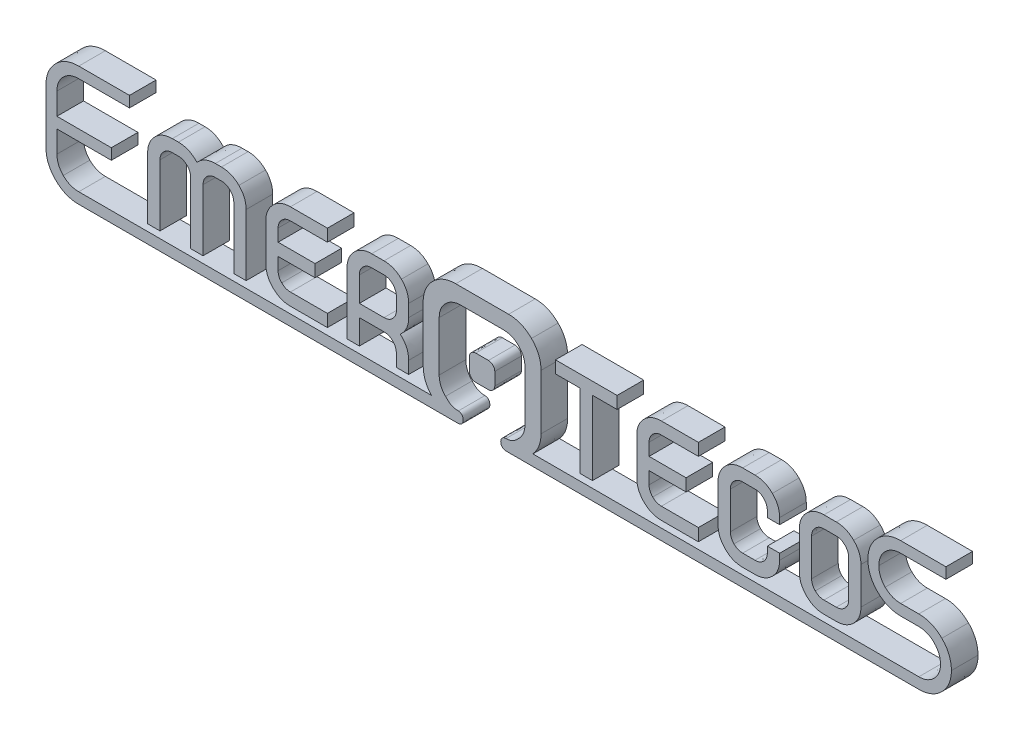
from build123d import *

# Parameters (mm, degrees)
RESSALTO_EXTRUS_O1_DEPTH   = 20
RESSALTO_EXTRUS_O1_2_DEPTH = 20
RESSALTO_EXTRUS_O1_3_DEPTH = 20
RESSALTO_EXTRUS_O1_4_DEPTH = 20
RESSALTO_EXTRUS_O1_5_DEPTH = 20
RESSALTO_EXTRUS_O1_6_DEPTH = 20
RESSALTO_EXTRUS_O1_7_DEPTH = 20
RESSALTO_EXTRUS_O1_8_DEPTH = 20
RESSALTO_EXTRUS_O1_9_DEPTH = 20


with BuildPart() as part:
    # Esboço1 → Ressalto-extrusão1 (new body)
    with BuildSketch(Plane.XY):
        with BuildLine():
            Line((31.801562, 20.64639), (31.801562, -20.646898))
            add(Edge.make_bspline(
                [(31.801562, -20.646898), (31.801562, -26.863802), (29.755084, -32.249618), (25.661874, -36.79825)],
                knots=[0.046153846, 0.046153846, 0.046153846, 0.046153846, 0.061538462, 0.061538462, 0.061538462, 0.061538462], degree=3))
            add(Edge.make_bspline(
                [(25.661874, -36.79825), (122.382026, -36.79825), (219.102432, -36.79825), (315.822584, -36.79825)],
                knots=[0.061538462, 0.061538462, 0.061538462, 0.061538462, 0.076923077, 0.076923077, 0.076923077, 0.076923077], degree=3))
            add(Edge.make_bspline(
                [(315.822584, -36.79825), (320.318384, -36.79825), (324.154546, -35.209988), (327.33107, -32.033718)],
                knots=[0.076923077, 0.076923077, 0.076923077, 0.076923077, 0.092307692, 0.092307692, 0.092307692, 0.092307692], degree=3))
            add(Edge.make_bspline(
                [(327.33107, -32.033718), (330.507594, -28.85694), (332.095856, -25.020778), (332.095856, -20.524978)],
                knots=[0.092307692, 0.092307692, 0.092307692, 0.092307692, 0.107692308, 0.107692308, 0.107692308, 0.107692308], degree=3))
            add(Edge.make_bspline(
                [(332.095856, -20.524978), (332.095856, -15.931134), (330.507594, -12.04595), (327.33107, -8.869426)],
                knots=[0.107692308, 0.107692308, 0.107692308, 0.107692308, 0.123076923, 0.123076923, 0.123076923, 0.123076923], degree=3))
            add(Edge.make_bspline(
                [(327.33107, -8.869426), (324.154546, -5.692902), (320.318384, -4.10464), (315.822584, -4.10464)],
                knots=[0.123076923, 0.123076923, 0.123076923, 0.123076923, 0.138461538, 0.138461538, 0.138461538, 0.138461538], degree=3))
            Line((315.822584, -4.10464), (302.187864, -4.10464))
            add(Edge.make_bspline(
                [(302.187864, -4.10464), (295.346374, -4.10464), (289.531044, -1.710182), (284.74162, 3.078734)],
                knots=[0.153846154, 0.153846154, 0.153846154, 0.153846154, 0.169230769, 0.169230769, 0.169230769, 0.169230769], degree=3))
            add(Edge.make_bspline(
                [(284.74162, 3.078734), (279.95245, 7.868158), (277.558246, 13.683488), (277.558246, 20.525232)],
                knots=[0.169230769, 0.169230769, 0.169230769, 0.169230769, 0.184615385, 0.184615385, 0.184615385, 0.184615385], degree=3))
            add(Edge.make_bspline(
                [(277.558246, 20.525232), (277.558246, 27.269186), (279.95245, 33.035748), (284.74162, 37.824918)],
                knots=[0.184615385, 0.184615385, 0.184615385, 0.184615385, 0.2, 0.2, 0.2, 0.2], degree=3))
            add(Edge.make_bspline(
                [(284.74162, 37.824918), (289.531044, 42.614088), (295.346374, 45.0088), (302.187864, 45.0088)],
                knots=[0.2, 0.2, 0.2, 0.2, 0.215384615, 0.215384615, 0.215384615, 0.215384615], degree=3))
            Line((302.187864, 45.0088), (336.201004, 45.0088))
            Line((336.201004, 45.0088), (336.201004, 36.798504))
            Line((336.201004, 36.798504), (302.187864, 36.798504))
            add(Edge.make_bspline(
                [(302.187864, 36.798504), (297.594274, 36.798504), (293.709344, 35.210242), (290.53282, 32.033718)],
                knots=[0.261538462, 0.261538462, 0.261538462, 0.261538462, 0.276923077, 0.276923077, 0.276923077, 0.276923077], degree=3))
            add(Edge.make_bspline(
                [(290.53282, 32.033718), (287.356296, 28.857448), (285.768034, 25.021032), (285.768034, 20.525232)],
                knots=[0.276923077, 0.276923077, 0.276923077, 0.276923077, 0.292307692, 0.292307692, 0.292307692, 0.292307692], degree=3))
            add(Edge.make_bspline(
                [(285.768034, 20.525232), (285.768034, 15.931388), (287.356296, 12.046458), (290.53282, 8.869934)],
                knots=[0.292307692, 0.292307692, 0.292307692, 0.292307692, 0.307692308, 0.307692308, 0.307692308, 0.307692308], degree=3))
            add(Edge.make_bspline(
                [(290.53282, 8.869934), (293.709344, 5.69341), (297.594274, 4.105148), (302.187864, 4.105148)],
                knots=[0.307692308, 0.307692308, 0.307692308, 0.307692308, 0.323076923, 0.323076923, 0.323076923, 0.323076923], degree=3))
            Line((302.187864, 4.105148), (315.822584, 4.105148))
            add(Edge.make_bspline(
                [(315.822584, 4.105148), (322.566284, 4.105148), (328.3331, 1.710436), (333.12227, -3.078734)],
                knots=[0.338461538, 0.338461538, 0.338461538, 0.338461538, 0.353846154, 0.353846154, 0.353846154, 0.353846154], degree=3))
            add(Edge.make_bspline(
                [(333.12227, -3.078734), (337.91144, -7.86765), (340.306152, -13.683234), (340.306152, -20.524978)],
                knots=[0.353846154, 0.353846154, 0.353846154, 0.353846154, 0.369230769, 0.369230769, 0.369230769, 0.369230769], degree=3))
            add(Edge.make_bspline(
                [(340.306152, -20.524978), (340.306152, -27.268678), (337.91144, -33.03524), (333.12227, -37.82441)],
                knots=[0.369230769, 0.369230769, 0.369230769, 0.369230769, 0.384615385, 0.384615385, 0.384615385, 0.384615385], degree=3))
            add(Edge.make_bspline(
                [(333.12227, -37.82441), (328.3331, -42.61358), (322.566284, -45.008292), (315.822584, -45.008292)],
                knots=[0.384615385, 0.384615385, 0.384615385, 0.384615385, 0.4, 0.4, 0.4, 0.4], degree=3))
            add(Edge.make_bspline(
                [(315.822584, -45.008292), (212.438996, -45.00753), (109.055408, -45.008038), (5.67182, -45.008038)],
                knots=[0.4, 0.4, 0.4, 0.4, 0.415384615, 0.415384615, 0.415384615, 0.415384615], degree=3))
            add(Edge.make_bspline(
                [(5.67182, -45.008038), (0.098044, -45.019722), (0.254254, -36.839144), (5.551678, -36.839144)],
                knots=[0.415384615, 0.415384615, 0.415384615, 0.415384615, 0.430769231, 0.430769231, 0.430769231, 0.430769231], degree=3))
            add(Edge.make_bspline(
                [(5.551678, -36.839144), (10.263378, -36.676076), (11.735562, -35.372802), (15.010384, -32.098234)],
                knots=[0.430769231, 0.430769231, 0.430769231, 0.430769231, 0.446153846, 0.446153846, 0.446153846, 0.446153846], degree=3))
            add(Edge.make_bspline(
                [(15.010384, -32.098234), (18.170906, -28.937458), (19.751294, -25.1206), (19.751294, -20.646898)],
                knots=[0.446153846, 0.446153846, 0.446153846, 0.446153846, 0.461538462, 0.461538462, 0.461538462, 0.461538462], degree=3))
            Line((19.751294, -20.646898), (19.751294, 16.765524))
            add(Edge.make_bspline(
                [(19.751294, 16.765524), (19.751294, 21.238972), (18.170906, 25.056338), (15.010384, 28.21686)],
                knots=[0.476923077, 0.476923077, 0.476923077, 0.476923077, 0.492307692, 0.492307692, 0.492307692, 0.492307692], degree=3))
            add(Edge.make_bspline(
                [(15.010384, 28.21686), (11.849608, 31.377382), (8.029956, 32.95777), (3.559048, 32.95777)],
                knots=[0.492307692, 0.492307692, 0.492307692, 0.492307692, 0.507692308, 0.507692308, 0.507692308, 0.507692308], degree=3))
            Line((3.559048, 32.95777), (-28.38831, 32.95777))
            add(Edge.make_bspline(
                [(-28.38831, 32.95777), (-32.9565, 32.95777), (-36.824666, 31.377382), (-39.985442, 28.21686)],
                knots=[0.523076923, 0.523076923, 0.523076923, 0.523076923, 0.538461538, 0.538461538, 0.538461538, 0.538461538], degree=3))
            add(Edge.make_bspline(
                [(-39.985442, 28.21686), (-43.145964, 25.056338), (-44.726098, 21.237956), (-44.726098, 16.765524)],
                knots=[0.538461538, 0.538461538, 0.538461538, 0.538461538, 0.553846154, 0.553846154, 0.553846154, 0.553846154], degree=3))
            Line((-44.726098, 16.765524), (-44.726098, -20.646898))
            add(Edge.make_bspline(
                [(-44.726098, -20.646898), (-44.726098, -25.119584), (-43.145964, -28.937458), (-39.985442, -32.098234)],
                knots=[0.569230769, 0.569230769, 0.569230769, 0.569230769, 0.584615385, 0.584615385, 0.584615385, 0.584615385], degree=3))
            add(Edge.make_bspline(
                [(-39.985442, -32.098234), (-36.663376, -35.419792), (-35.146488, -36.678108), (-30.38094, -36.839144)],
                knots=[0.584615385, 0.584615385, 0.584615385, 0.584615385, 0.6, 0.6, 0.6, 0.6], degree=3))
            add(Edge.make_bspline(
                [(-30.38094, -36.839144), (-25.404826, -36.839144), (-25.404826, -45.008292), (-30.38094, -45.008292)],
                knots=[0.6, 0.6, 0.6, 0.6, 0.615384615, 0.615384615, 0.615384615, 0.615384615], degree=3))
            add(Edge.make_bspline(
                [(-30.38094, -45.008292), (-125.479302, -45.008292), (-220.577918, -45.008292), (-315.67628, -45.008292)],
                knots=[0.615384615, 0.615384615, 0.615384615, 0.615384615, 0.630769231, 0.630769231, 0.630769231, 0.630769231], degree=3))
            add(Edge.make_bspline(
                [(-315.67628, -45.008292), (-322.51777, -45.008292), (-328.333354, -42.61358), (-333.12227, -37.82441)],
                knots=[0.630769231, 0.630769231, 0.630769231, 0.630769231, 0.646153846, 0.646153846, 0.646153846, 0.646153846], degree=3))
            add(Edge.make_bspline(
                [(-333.12227, -37.82441), (-337.91144, -33.035494), (-340.305898, -27.268678), (-340.305898, -20.524978)],
                knots=[0.646153846, 0.646153846, 0.646153846, 0.646153846, 0.661538462, 0.661538462, 0.661538462, 0.661538462], degree=3))
            Line((-340.305898, -20.524978), (-340.305898, 20.524724))
            add(Edge.make_bspline(
                [(-340.305898, 20.524724), (-340.305898, 27.268424), (-337.91144, 33.03524), (-333.12227, 37.824156)],
                knots=[0.676923077, 0.676923077, 0.676923077, 0.676923077, 0.692307692, 0.692307692, 0.692307692, 0.692307692], degree=3))
            add(Edge.make_bspline(
                [(-333.12227, 37.824156), (-328.333354, 42.613326), (-322.51777, 45.008038), (-315.67628, 45.008038)],
                knots=[0.692307692, 0.692307692, 0.692307692, 0.692307692, 0.707692308, 0.707692308, 0.707692308, 0.707692308], degree=3))
            Line((-315.67628, 45.008038), (-277.5585, 45.008038))
            Line((-277.5585, 45.008038), (-277.5585, 36.797742))
            Line((-277.5585, 36.797742), (-315.67628, 36.797742))
            add(Edge.make_bspline(
                [(-315.67628, 36.797742), (-320.26987, 36.797742), (-324.1548, 35.209734), (-327.331324, 32.03321)],
                knots=[0.753846154, 0.753846154, 0.753846154, 0.753846154, 0.769230769, 0.769230769, 0.769230769, 0.769230769], degree=3))
            add(Edge.make_bspline(
                [(-327.331324, 32.03321), (-330.507848, 28.856686), (-332.095856, 25.020524), (-332.095856, 20.524724)],
                knots=[0.769230769, 0.769230769, 0.769230769, 0.769230769, 0.784615385, 0.784615385, 0.784615385, 0.784615385], degree=3))
            Line((-332.095856, 20.524724), (-332.095856, 4.104894))
            Line((-332.095856, 4.104894), (-291.192966, 4.104894))
            Line((-291.192966, 4.104894), (-291.192966, -4.105148))
            Line((-291.192966, -4.105148), (-332.095856, -4.105148))
            Line((-332.095856, -4.105148), (-332.095856, -20.524978))
            add(Edge.make_bspline(
                [(-332.095856, -20.524978), (-332.095856, -25.021032), (-330.507848, -28.85694), (-327.331324, -32.033718)],
                knots=[0.861538462, 0.861538462, 0.861538462, 0.861538462, 0.876923077, 0.876923077, 0.876923077, 0.876923077], degree=3))
            add(Edge.make_bspline(
                [(-327.331324, -32.033718), (-324.1548, -35.210242), (-320.26987, -36.798504), (-315.67628, -36.798504)],
                knots=[0.876923077, 0.876923077, 0.876923077, 0.876923077, 0.892307692, 0.892307692, 0.892307692, 0.892307692], degree=3))
            add(Edge.make_bspline(
                [(-315.67628, -36.798504), (-227.329746, -36.798504), (-138.982958, -36.798504), (-50.636424, -36.798504)],
                knots=[0.892307692, 0.892307692, 0.892307692, 0.892307692, 0.907692308, 0.907692308, 0.907692308, 0.907692308], degree=3))
            add(Edge.make_bspline(
                [(-50.636424, -36.798504), (-54.729888, -32.250126), (-56.776366, -26.866342), (-56.776366, -20.646898)],
                knots=[0.907692308, 0.907692308, 0.907692308, 0.907692308, 0.923076923, 0.923076923, 0.923076923, 0.923076923], degree=3))
            Line((-56.776366, -20.646898), (-56.776366, 20.64639))
            add(Edge.make_bspline(
                [(-56.776366, 20.64639), (-56.776366, 27.356562), (-54.393846, 33.094422), (-49.628552, 37.859716)],
                knots=[0.938461538, 0.938461538, 0.938461538, 0.938461538, 0.953846154, 0.953846154, 0.953846154, 0.953846154], degree=3))
            add(Edge.make_bspline(
                [(-49.628552, 37.859716), (-44.863258, 42.62501), (-39.076884, 45.007784), (-32.26943, 45.007784)],
                knots=[0.953846154, 0.953846154, 0.953846154, 0.953846154, 0.969230769, 0.969230769, 0.969230769, 0.969230769], degree=3))
            Line((-32.26943, 45.007784), (7.440422, 45.007784))
            add(Edge.make_bspline(
                [(7.440422, 45.007784), (14.150594, 45.007784), (19.888454, 42.62501), (24.653748, 37.859716)],
                knots=[0, 0, 0, 0, 0.015384615, 0.015384615, 0.015384615, 0.015384615], degree=3))
            add(Edge.make_bspline(
                [(24.653748, 37.859716), (29.419042, 33.094422), (31.801562, 27.354276), (31.801562, 20.64639)],
                knots=[0.015384615, 0.015384615, 0.015384615, 0.015384615, 0.030769231, 0.030769231, 0.030769231, 0.030769231], degree=3))
        make_face()
    extrude(amount=RESSALTO_EXTRUS_O1_DEPTH)


with BuildPart() as body_2:
    # Esboço1 → Ressalto-extrus_o1 2 (new body)
    with BuildSketch(Plane.XY):
        with BuildLine():
            Line((-17.256252, 7.376922), (-7.718044, 7.376922))
            add(Edge.make_bspline(
                [(-7.718044, 7.376922), (-5.094986, 7.376922), (-2.949194, 5.23113), (-2.949194, 2.608326)],
                knots=[0.111111111, 0.111111111, 0.111111111, 0.111111111, 0.222222222, 0.222222222, 0.222222222, 0.222222222], degree=3))
            Line((-2.949194, 2.608326), (-2.949194, -6.930136))
            add(Edge.make_bspline(
                [(-2.949194, -6.930136), (-2.949194, -9.55294), (-5.094986, -11.698732), (-7.718044, -11.698732)],
                knots=[0.333333333, 0.333333333, 0.333333333, 0.333333333, 0.444444444, 0.444444444, 0.444444444, 0.444444444], degree=3))
            Line((-7.718044, -11.698732), (-17.256252, -11.698732))
            add(Edge.make_bspline(
                [(-17.256252, -11.698732), (-19.879056, -11.698732), (-22.024848, -9.55294), (-22.024848, -6.930136)],
                knots=[0.555555556, 0.555555556, 0.555555556, 0.555555556, 0.666666667, 0.666666667, 0.666666667, 0.666666667], degree=3))
            Line((-22.024848, -6.930136), (-22.024848, 2.608326))
            add(Edge.make_bspline(
                [(-22.024848, 2.608326), (-22.024848, 5.23113), (-19.879056, 7.376922), (-17.256252, 7.376922)],
                knots=[0.777777778, 0.777777778, 0.777777778, 0.777777778, 1, 1, 1, 1], degree=3))
        make_face()
    extrude(amount=RESSALTO_EXTRUS_O1_2_DEPTH)


with BuildPart() as body_3:
    # Esboço1 → Ressalto-extrus_o1 3 (new body)
    with BuildSketch(Plane.XY):
        with BuildLine():
            Line((253.772416, -31.785052), (244.508528, -31.785052))
            add(Edge.make_bspline(
                [(244.508528, -31.785052), (239.373664, -31.785052), (235.001816, -29.980636), (231.393492, -26.372312)],
                knots=[0.230769231, 0.230769231, 0.230769231, 0.230769231, 0.307692308, 0.307692308, 0.307692308, 0.307692308], degree=3))
            add(Edge.make_bspline(
                [(231.393492, -26.372312), (227.785168, -22.763988), (225.981006, -18.392394), (225.981006, -13.257276)],
                knots=[0.307692308, 0.307692308, 0.307692308, 0.307692308, 0.384615385, 0.384615385, 0.384615385, 0.384615385], degree=3))
            Line((225.981006, -13.257276), (225.981006, 14.534134))
            add(Edge.make_bspline(
                [(225.981006, 14.534134), (225.981006, 19.59991), (227.785168, 23.936706), (231.393492, 27.545284)],
                knots=[0.461538462, 0.461538462, 0.461538462, 0.461538462, 0.538461538, 0.538461538, 0.538461538, 0.538461538], degree=3))
            add(Edge.make_bspline(
                [(231.393492, 27.545284), (235.001816, 31.153608), (239.373664, 32.95777), (244.508528, 32.95777)],
                knots=[0.538461538, 0.538461538, 0.538461538, 0.538461538, 0.615384615, 0.615384615, 0.615384615, 0.615384615], degree=3))
            Line((244.508528, 32.95777), (253.772416, 32.95777))
            add(Edge.make_bspline(
                [(253.772416, 32.95777), (258.837938, 32.95777), (263.19226, 31.153608), (266.835382, 27.545284)],
                knots=[0.692307692, 0.692307692, 0.692307692, 0.692307692, 0.769230769, 0.769230769, 0.769230769, 0.769230769], degree=3))
            add(Edge.make_bspline(
                [(266.835382, 27.545284), (270.478504, 23.936706), (272.300192, 19.59991), (272.300192, 14.534134)],
                knots=[0.769230769, 0.769230769, 0.769230769, 0.769230769, 0.846153846, 0.846153846, 0.846153846, 0.846153846], degree=3))
            Line((272.300192, 14.534134), (272.300192, -13.257276))
            add(Edge.make_bspline(
                [(272.300192, -13.257276), (272.300192, -18.392394), (270.478504, -22.763988), (266.835382, -26.372312)],
                knots=[0, 0, 0, 0, 0.076923077, 0.076923077, 0.076923077, 0.076923077], degree=3))
            add(Edge.make_bspline(
                [(266.835382, -26.372312), (263.19226, -29.980636), (258.837938, -31.785052), (253.772416, -31.785052)],
                knots=[0.076923077, 0.076923077, 0.076923077, 0.076923077, 0.153846154, 0.153846154, 0.153846154, 0.153846154], degree=3))
        make_face()
        with BuildLine():
            Line((263.036304, -13.257276), (263.036304, 14.534134))
            add(Edge.make_bspline(
                [(263.036304, 14.534134), (263.036304, 17.032224), (262.134096, 19.200876), (260.329934, 21.039836)],
                knots=[0.076923077, 0.076923077, 0.076923077, 0.076923077, 0.153846154, 0.153846154, 0.153846154, 0.153846154], degree=3))
            add(Edge.make_bspline(
                [(260.329934, 21.039836), (258.525772, 22.878542), (256.339848, 23.798022), (253.772416, 23.798022)],
                knots=[0.153846154, 0.153846154, 0.153846154, 0.153846154, 0.230769231, 0.230769231, 0.230769231, 0.230769231], degree=3))
            Line((253.772416, 23.798022), (244.508528, 23.798022))
            add(Edge.make_bspline(
                [(244.508528, 23.798022), (241.941096, 23.798022), (239.755172, 22.878542), (237.95101, 21.039836)],
                knots=[0.307692308, 0.307692308, 0.307692308, 0.307692308, 0.384615385, 0.384615385, 0.384615385, 0.384615385], degree=3))
            add(Edge.make_bspline(
                [(237.95101, 21.039836), (236.146594, 19.200876), (235.24464, 17.032224), (235.24464, 14.534134)],
                knots=[0.384615385, 0.384615385, 0.384615385, 0.384615385, 0.461538462, 0.461538462, 0.461538462, 0.461538462], degree=3))
            Line((235.24464, 14.534134), (235.24464, -13.257276))
            add(Edge.make_bspline(
                [(235.24464, -13.257276), (235.24464, -15.824962), (236.146594, -18.010632), (237.95101, -19.815048)],
                knots=[0.538461538, 0.538461538, 0.538461538, 0.538461538, 0.615384615, 0.615384615, 0.615384615, 0.615384615], degree=3))
            add(Edge.make_bspline(
                [(237.95101, -19.815048), (239.755172, -21.618956), (241.941096, -22.521164), (244.508528, -22.521164)],
                knots=[0.615384615, 0.615384615, 0.615384615, 0.615384615, 0.692307692, 0.692307692, 0.692307692, 0.692307692], degree=3))
            Line((244.508528, -22.521164), (253.772416, -22.521164))
            add(Edge.make_bspline(
                [(253.772416, -22.521164), (256.339848, -22.521164), (258.525772, -21.618956), (260.329934, -19.815048)],
                knots=[0.769230769, 0.769230769, 0.769230769, 0.769230769, 0.846153846, 0.846153846, 0.846153846, 0.846153846], degree=3))
            add(Edge.make_bspline(
                [(260.329934, -19.815048), (262.134096, -18.010632), (263.036304, -15.824962), (263.036304, -13.257276)],
                knots=[0.846153846, 0.846153846, 0.846153846, 0.846153846, 1, 1, 1, 1], degree=3))
        make_face(mode=Mode.SUBTRACT)
    extrude(amount=RESSALTO_EXTRUS_O1_3_DEPTH)


with BuildPart() as body_4:
    # Esboço1 → Ressalto-extrus_o1 4 (new body)
    with BuildSketch(Plane.XY):
        with BuildLine():
            Line((-67.67576, -31.785052), (-76.939648, -31.785052))
            Line((-76.939648, -31.785052), (-76.939648, -22.521164))
            add(Edge.make_bspline(
                [(-76.939648, -22.521164), (-76.939648, -19.953732), (-77.841856, -17.767808), (-79.646018, -15.963646)],
                knots=[0.111111111, 0.111111111, 0.111111111, 0.111111111, 0.166666667, 0.166666667, 0.166666667, 0.166666667], degree=3))
            add(Edge.make_bspline(
                [(-79.646018, -15.963646), (-81.450434, -14.159484), (-83.636104, -13.257276), (-86.203536, -13.257276)],
                knots=[0.166666667, 0.166666667, 0.166666667, 0.166666667, 0.222222222, 0.222222222, 0.222222222, 0.222222222], degree=3))
            Line((-86.203536, -13.257276), (-104.731312, -13.257276))
            Line((-104.731312, -13.257276), (-104.731312, -31.785052))
            Line((-104.731312, -31.785052), (-113.994946, -31.785052))
            Line((-113.994946, -31.785052), (-113.994946, 14.534134))
            add(Edge.make_bspline(
                [(-113.994946, 14.534134), (-113.994946, 19.59991), (-112.190784, 23.936706), (-108.58246, 27.545284)],
                knots=[0.444444444, 0.444444444, 0.444444444, 0.444444444, 0.5, 0.5, 0.5, 0.5], degree=3))
            add(Edge.make_bspline(
                [(-108.58246, 27.545284), (-104.974136, 31.153608), (-100.602288, 32.95777), (-95.467424, 32.95777)],
                knots=[0.5, 0.5, 0.5, 0.5, 0.555555556, 0.555555556, 0.555555556, 0.555555556], degree=3))
            Line((-95.467424, 32.95777), (-86.203536, 32.95777))
            add(Edge.make_bspline(
                [(-86.203536, 32.95777), (-81.138014, 32.95777), (-76.783692, 31.153608), (-73.14057, 27.545284)],
                knots=[0.611111111, 0.611111111, 0.611111111, 0.611111111, 0.666666667, 0.666666667, 0.666666667, 0.666666667], degree=3))
            add(Edge.make_bspline(
                [(-73.14057, 27.545284), (-69.497448, 23.936706), (-67.67576, 19.59991), (-67.67576, 14.534134)],
                knots=[0.666666667, 0.666666667, 0.666666667, 0.666666667, 0.722222222, 0.722222222, 0.722222222, 0.722222222], degree=3))
            Line((-67.67576, 14.534134), (-67.67576, 5.2705))
            add(Edge.make_bspline(
                [(-67.67576, 5.2705), (-67.67576, -0.350266), (-69.792342, -4.999736), (-74.025506, -8.677402)],
                knots=[0.777777778, 0.777777778, 0.777777778, 0.777777778, 0.833333333, 0.833333333, 0.833333333, 0.833333333], degree=3))
            add(Edge.make_bspline(
                [(-74.025506, -8.677402), (-69.792342, -12.355068), (-67.67576, -16.96974), (-67.67576, -22.521164)],
                knots=[0.833333333, 0.833333333, 0.833333333, 0.833333333, 0.888888889, 0.888888889, 0.888888889, 0.888888889], degree=3))
            Line((-67.67576, -22.521164), (-67.67576, -31.785052))
        make_face()
        with BuildLine():
            Line((-76.939648, 5.2705), (-76.939648, 14.534134))
            add(Edge.make_bspline(
                [(-76.939648, 14.534134), (-76.939648, 17.032224), (-77.841856, 19.200876), (-79.646018, 21.039836)],
                knots=[0.090909091, 0.090909091, 0.090909091, 0.090909091, 0.181818182, 0.181818182, 0.181818182, 0.181818182], degree=3))
            add(Edge.make_bspline(
                [(-79.646018, 21.039836), (-81.450434, 22.878542), (-83.636104, 23.798022), (-86.203536, 23.798022)],
                knots=[0.181818182, 0.181818182, 0.181818182, 0.181818182, 0.272727273, 0.272727273, 0.272727273, 0.272727273], degree=3))
            Line((-86.203536, 23.798022), (-95.467424, 23.798022))
            add(Edge.make_bspline(
                [(-95.467424, 23.798022), (-98.034856, 23.798022), (-100.22078, 22.878542), (-102.024942, 21.039836)],
                knots=[0.363636364, 0.363636364, 0.363636364, 0.363636364, 0.454545455, 0.454545455, 0.454545455, 0.454545455], degree=3))
            add(Edge.make_bspline(
                [(-102.024942, 21.039836), (-103.829358, 19.200876), (-104.731312, 17.032224), (-104.731312, 14.534134)],
                knots=[0.454545455, 0.454545455, 0.454545455, 0.454545455, 0.545454545, 0.545454545, 0.545454545, 0.545454545], degree=3))
            Line((-104.731312, 14.534134), (-104.731312, -3.993388))
            Line((-104.731312, -3.993388), (-86.203536, -3.993388))
            add(Edge.make_bspline(
                [(-86.203536, -3.993388), (-83.636104, -3.993388), (-81.450434, -3.091434), (-79.646018, -1.287018)],
                knots=[0.727272727, 0.727272727, 0.727272727, 0.727272727, 0.818181818, 0.818181818, 0.818181818, 0.818181818], degree=3))
            add(Edge.make_bspline(
                [(-79.646018, -1.287018), (-77.841856, 0.517144), (-76.939648, 2.703068), (-76.939648, 5.2705)],
                knots=[0.818181818, 0.818181818, 0.818181818, 0.818181818, 1, 1, 1, 1], degree=3))
        make_face(mode=Mode.SUBTRACT)
    extrude(amount=RESSALTO_EXTRUS_O1_4_DEPTH)


with BuildPart() as body_5:
    # Esboço1 → Ressalto-extrus_o1 5 (new body)
    with BuildSketch(Plane.XY):
        with BuildLine():
            Line((192.672716, -31.785052), (183.408828, -31.785052))
            add(Edge.make_bspline(
                [(183.408828, -31.785052), (178.273964, -31.785052), (173.90237, -29.980636), (170.293792, -26.372312)],
                knots=[0.103448276, 0.103448276, 0.103448276, 0.103448276, 0.137931034, 0.137931034, 0.137931034, 0.137931034], degree=3))
            add(Edge.make_bspline(
                [(170.293792, -26.372312), (166.685468, -22.763988), (164.881306, -18.392394), (164.881306, -13.257276)],
                knots=[0.137931034, 0.137931034, 0.137931034, 0.137931034, 0.172413793, 0.172413793, 0.172413793, 0.172413793], degree=3))
            Line((164.881306, -13.257276), (164.881306, 14.534134))
            add(Edge.make_bspline(
                [(164.881306, 14.534134), (164.881306, 19.59991), (166.685468, 23.936706), (170.293792, 27.545284)],
                knots=[0.206896552, 0.206896552, 0.206896552, 0.206896552, 0.24137931, 0.24137931, 0.24137931, 0.24137931], degree=3))
            add(Edge.make_bspline(
                [(170.293792, 27.545284), (173.90237, 31.153608), (178.273964, 32.95777), (183.408828, 32.95777)],
                knots=[0.24137931, 0.24137931, 0.24137931, 0.24137931, 0.275862069, 0.275862069, 0.275862069, 0.275862069], degree=3))
            Line((183.408828, 32.95777), (192.672716, 32.95777))
            add(Edge.make_bspline(
                [(192.672716, 32.95777), (197.738492, 32.95777), (202.092814, 31.153608), (205.735682, 27.545284)],
                knots=[0.310344828, 0.310344828, 0.310344828, 0.310344828, 0.344827586, 0.344827586, 0.344827586, 0.344827586], degree=3))
            add(Edge.make_bspline(
                [(205.735682, 27.545284), (209.378804, 23.936706), (211.200492, 19.59991), (211.200492, 14.534134)],
                knots=[0.344827586, 0.344827586, 0.344827586, 0.344827586, 0.379310345, 0.379310345, 0.379310345, 0.379310345], degree=3))
            Line((211.200492, 14.534134), (211.200492, 9.85012))
            Line((211.200492, 9.85012), (201.936858, 9.85012))
            Line((201.936858, 9.85012), (201.936858, 14.534134))
            add(Edge.make_bspline(
                [(201.936858, 14.534134), (201.936858, 17.032224), (201.034396, 19.200876), (199.230234, 21.039836)],
                knots=[0.482758621, 0.482758621, 0.482758621, 0.482758621, 0.517241379, 0.517241379, 0.517241379, 0.517241379], degree=3))
            add(Edge.make_bspline(
                [(199.230234, 21.039836), (197.426072, 22.878542), (195.240148, 23.798022), (192.672716, 23.798022)],
                knots=[0.517241379, 0.517241379, 0.517241379, 0.517241379, 0.551724138, 0.551724138, 0.551724138, 0.551724138], degree=3))
            Line((192.672716, 23.798022), (183.408828, 23.798022))
            add(Edge.make_bspline(
                [(183.408828, 23.798022), (180.841396, 23.798022), (178.655472, 22.878542), (176.85131, 21.039836)],
                knots=[0.586206897, 0.586206897, 0.586206897, 0.586206897, 0.620689655, 0.620689655, 0.620689655, 0.620689655], degree=3))
            add(Edge.make_bspline(
                [(176.85131, 21.039836), (175.047148, 19.200876), (174.145194, 17.032224), (174.145194, 14.534134)],
                knots=[0.620689655, 0.620689655, 0.620689655, 0.620689655, 0.655172414, 0.655172414, 0.655172414, 0.655172414], degree=3))
            Line((174.145194, 14.534134), (174.145194, -13.257276))
            add(Edge.make_bspline(
                [(174.145194, -13.257276), (174.145194, -15.824962), (175.047148, -18.010632), (176.85131, -19.815048)],
                knots=[0.689655172, 0.689655172, 0.689655172, 0.689655172, 0.724137931, 0.724137931, 0.724137931, 0.724137931], degree=3))
            add(Edge.make_bspline(
                [(176.85131, -19.815048), (178.655472, -21.618956), (180.841396, -22.521164), (183.408828, -22.521164)],
                knots=[0.724137931, 0.724137931, 0.724137931, 0.724137931, 0.75862069, 0.75862069, 0.75862069, 0.75862069], degree=3))
            Line((183.408828, -22.521164), (192.672716, -22.521164))
            add(Edge.make_bspline(
                [(192.672716, -22.521164), (195.240148, -22.521164), (197.426072, -21.618956), (199.230234, -19.815048)],
                knots=[0.793103448, 0.793103448, 0.793103448, 0.793103448, 0.827586207, 0.827586207, 0.827586207, 0.827586207], degree=3))
            add(Edge.make_bspline(
                [(199.230234, -19.815048), (201.034396, -18.010632), (201.936858, -15.824962), (201.936858, -13.257276)],
                knots=[0.827586207, 0.827586207, 0.827586207, 0.827586207, 0.862068966, 0.862068966, 0.862068966, 0.862068966], degree=3))
            Line((201.936858, -13.257276), (201.936858, -8.677402))
            Line((201.936858, -8.677402), (211.200492, -8.677402))
            Line((211.200492, -8.677402), (211.200492, -13.257276))
            add(Edge.make_bspline(
                [(211.200492, -13.257276), (211.200492, -18.392394), (209.378804, -22.763988), (205.735682, -26.372312)],
                knots=[0, 0, 0, 0, 0.034482759, 0.034482759, 0.034482759, 0.034482759], degree=3))
            add(Edge.make_bspline(
                [(205.735682, -26.372312), (202.092814, -29.980636), (197.738492, -31.785052), (192.672716, -31.785052)],
                knots=[0.034482759, 0.034482759, 0.034482759, 0.034482759, 0.068965517, 0.068965517, 0.068965517, 0.068965517], degree=3))
        make_face()
    extrude(amount=RESSALTO_EXTRUS_O1_5_DEPTH)


with BuildPart() as body_6:
    # Esboço1 → Ressalto-extrus_o1 6 (new body)
    with BuildSketch(Plane.XY):
        with BuildLine():
            Line((150.101046, -31.785052), (122.309382, -31.785052))
            add(Edge.make_bspline(
                [(122.309382, -31.785052), (117.174264, -31.785052), (112.80267, -29.980636), (109.194092, -26.372312)],
                knots=[0.047619048, 0.047619048, 0.047619048, 0.047619048, 0.095238095, 0.095238095, 0.095238095, 0.095238095], degree=3))
            add(Edge.make_bspline(
                [(109.194092, -26.372312), (105.586022, -22.763988), (103.78186, -18.392394), (103.78186, -13.257276)],
                knots=[0.095238095, 0.095238095, 0.095238095, 0.095238095, 0.142857143, 0.142857143, 0.142857143, 0.142857143], degree=3))
            Line((103.78186, -13.257276), (103.78186, 14.534134))
            add(Edge.make_bspline(
                [(103.78186, 14.534134), (103.78186, 19.59991), (105.586022, 23.936706), (109.194092, 27.545284)],
                knots=[0.19047619, 0.19047619, 0.19047619, 0.19047619, 0.238095238, 0.238095238, 0.238095238, 0.238095238], degree=3))
            add(Edge.make_bspline(
                [(109.194092, 27.545284), (112.80267, 31.153608), (117.174264, 32.95777), (122.309382, 32.95777)],
                knots=[0.238095238, 0.238095238, 0.238095238, 0.238095238, 0.285714286, 0.285714286, 0.285714286, 0.285714286], degree=3))
            Line((122.309382, 32.95777), (150.101046, 32.95777))
            Line((150.101046, 32.95777), (150.101046, 23.798022))
            Line((150.101046, 23.798022), (122.309382, 23.798022))
            add(Edge.make_bspline(
                [(122.309382, 23.798022), (119.74195, 23.798022), (117.556026, 22.878542), (115.751864, 21.039836)],
                knots=[0.428571429, 0.428571429, 0.428571429, 0.428571429, 0.476190476, 0.476190476, 0.476190476, 0.476190476], degree=3))
            add(Edge.make_bspline(
                [(115.751864, 21.039836), (113.947448, 19.200876), (113.045494, 17.032224), (113.045494, 14.534134)],
                knots=[0.476190476, 0.476190476, 0.476190476, 0.476190476, 0.523809524, 0.523809524, 0.523809524, 0.523809524], degree=3))
            Line((113.045494, 14.534134), (113.045494, 5.2705))
            Line((113.045494, 5.2705), (140.837158, 5.2705))
            Line((140.837158, 5.2705), (140.837158, -3.993388))
            Line((140.837158, -3.993388), (113.045494, -3.993388))
            Line((113.045494, -3.993388), (113.045494, -13.257276))
            add(Edge.make_bspline(
                [(113.045494, -13.257276), (113.045494, -15.824962), (113.947448, -18.010632), (115.751864, -19.815048)],
                knots=[0.761904762, 0.761904762, 0.761904762, 0.761904762, 0.80952381, 0.80952381, 0.80952381, 0.80952381], degree=3))
            add(Edge.make_bspline(
                [(115.751864, -19.815048), (117.556026, -21.618956), (119.74195, -22.521164), (122.309382, -22.521164)],
                knots=[0.80952381, 0.80952381, 0.80952381, 0.80952381, 0.857142857, 0.857142857, 0.857142857, 0.857142857], degree=3))
            Line((122.309382, -22.521164), (150.101046, -22.521164))
            Line((150.101046, -22.521164), (150.101046, -31.785052))
        make_face()
    extrude(amount=RESSALTO_EXTRUS_O1_6_DEPTH)


with BuildPart() as body_7:
    # Esboço1 → Ressalto-extrus_o1 7 (new body)
    with BuildSketch(Plane.XY):
        Polygon((89.001346, 23.798022), (70.47357, 23.798022), (70.47357, -31.785052), (61.209682, -31.785052), (61.209682, 23.798022), (42.68216, 23.798022), (42.68216, 32.95777), (89.001346, 32.95777), align=None)
    extrude(amount=RESSALTO_EXTRUS_O1_7_DEPTH)


with BuildPart() as body_8:
    # Esboço1 → Ressalto-extrus_o1 8 (new body)
    with BuildSketch(Plane.XY):
        with BuildLine():
            Line((-128.77546, -31.785052), (-156.567124, -31.785052))
            add(Edge.make_bspline(
                [(-156.567124, -31.785052), (-161.701988, -31.785052), (-166.073836, -29.980636), (-169.68216, -26.372312)],
                knots=[0.047619048, 0.047619048, 0.047619048, 0.047619048, 0.095238095, 0.095238095, 0.095238095, 0.095238095], degree=3))
            add(Edge.make_bspline(
                [(-169.68216, -26.372312), (-173.290484, -22.763988), (-175.094646, -18.392394), (-175.094646, -13.257276)],
                knots=[0.095238095, 0.095238095, 0.095238095, 0.095238095, 0.142857143, 0.142857143, 0.142857143, 0.142857143], degree=3))
            Line((-175.094646, -13.257276), (-175.094646, 14.534134))
            add(Edge.make_bspline(
                [(-175.094646, 14.534134), (-175.094646, 19.59991), (-173.290484, 23.936706), (-169.68216, 27.545284)],
                knots=[0.19047619, 0.19047619, 0.19047619, 0.19047619, 0.238095238, 0.238095238, 0.238095238, 0.238095238], degree=3))
            add(Edge.make_bspline(
                [(-169.68216, 27.545284), (-166.073836, 31.153608), (-161.701988, 32.95777), (-156.567124, 32.95777)],
                knots=[0.238095238, 0.238095238, 0.238095238, 0.238095238, 0.285714286, 0.285714286, 0.285714286, 0.285714286], degree=3))
            Line((-156.567124, 32.95777), (-128.77546, 32.95777))
            Line((-128.77546, 32.95777), (-128.77546, 23.798022))
            Line((-128.77546, 23.798022), (-156.567124, 23.798022))
            add(Edge.make_bspline(
                [(-156.567124, 23.798022), (-159.134556, 23.798022), (-161.32048, 22.878542), (-163.124642, 21.039836)],
                knots=[0.428571429, 0.428571429, 0.428571429, 0.428571429, 0.476190476, 0.476190476, 0.476190476, 0.476190476], degree=3))
            add(Edge.make_bspline(
                [(-163.124642, 21.039836), (-164.928804, 19.200876), (-165.830758, 17.032224), (-165.830758, 14.534134)],
                knots=[0.476190476, 0.476190476, 0.476190476, 0.476190476, 0.523809524, 0.523809524, 0.523809524, 0.523809524], degree=3))
            Line((-165.830758, 14.534134), (-165.830758, 5.2705))
            Line((-165.830758, 5.2705), (-138.039094, 5.2705))
            Line((-138.039094, 5.2705), (-138.039094, -3.993388))
            Line((-138.039094, -3.993388), (-165.830758, -3.993388))
            Line((-165.830758, -3.993388), (-165.830758, -13.257276))
            add(Edge.make_bspline(
                [(-165.830758, -13.257276), (-165.830758, -15.824962), (-164.928804, -18.010632), (-163.124642, -19.815048)],
                knots=[0.761904762, 0.761904762, 0.761904762, 0.761904762, 0.80952381, 0.80952381, 0.80952381, 0.80952381], degree=3))
            add(Edge.make_bspline(
                [(-163.124642, -19.815048), (-161.32048, -21.618956), (-159.134556, -22.521164), (-156.567124, -22.521164)],
                knots=[0.80952381, 0.80952381, 0.80952381, 0.80952381, 0.857142857, 0.857142857, 0.857142857, 0.857142857], degree=3))
            Line((-156.567124, -22.521164), (-128.77546, -22.521164))
            Line((-128.77546, -22.521164), (-128.77546, -31.785052))
        make_face()
    extrude(amount=RESSALTO_EXTRUS_O1_8_DEPTH)


with BuildPart() as body_9:
    # Esboço1 → Ressalto-extrus_o1 9 (new body)
    with BuildSketch(Plane.XY):
        with BuildLine():
            Line((-189.87516, -31.785052), (-199.139048, -31.785052))
            Line((-199.139048, -31.785052), (-199.139048, 14.534134))
            add(Edge.make_bspline(
                [(-199.139048, 14.534134), (-199.139048, 17.032224), (-200.041002, 19.200876), (-201.845164, 21.039836)],
                knots=[0.071428571, 0.071428571, 0.071428571, 0.071428571, 0.107142857, 0.107142857, 0.107142857, 0.107142857], degree=3))
            add(Edge.make_bspline(
                [(-201.845164, 21.039836), (-203.64958, 22.878542), (-205.83525, 23.798022), (-208.402936, 23.798022)],
                knots=[0.107142857, 0.107142857, 0.107142857, 0.107142857, 0.142857143, 0.142857143, 0.142857143, 0.142857143], degree=3))
            Line((-208.402936, 23.798022), (-212.98281, 23.798022))
            add(Edge.make_bspline(
                [(-212.98281, 23.798022), (-215.550242, 23.798022), (-217.736166, 22.878542), (-219.540328, 21.039836)],
                knots=[0.178571429, 0.178571429, 0.178571429, 0.178571429, 0.214285714, 0.214285714, 0.214285714, 0.214285714], degree=3))
            add(Edge.make_bspline(
                [(-219.540328, 21.039836), (-221.344236, 19.200876), (-222.246698, 17.032224), (-222.246698, 14.534134)],
                knots=[0.214285714, 0.214285714, 0.214285714, 0.214285714, 0.25, 0.25, 0.25, 0.25], degree=3))
            Line((-222.246698, 14.534134), (-222.246698, -31.785052))
            Line((-222.246698, -31.785052), (-231.510332, -31.785052))
            Line((-231.510332, -31.785052), (-231.510332, 14.534134))
            add(Edge.make_bspline(
                [(-231.510332, 14.534134), (-231.510332, 17.032224), (-232.412286, 19.200876), (-234.216702, 21.039836)],
                knots=[0.357142857, 0.357142857, 0.357142857, 0.357142857, 0.392857143, 0.392857143, 0.392857143, 0.392857143], degree=3))
            add(Edge.make_bspline(
                [(-234.216702, 21.039836), (-236.020864, 22.878542), (-238.206788, 23.798022), (-240.77422, 23.798022)],
                knots=[0.392857143, 0.392857143, 0.392857143, 0.392857143, 0.428571429, 0.428571429, 0.428571429, 0.428571429], degree=3))
            Line((-240.77422, 23.798022), (-245.354094, 23.798022))
            add(Edge.make_bspline(
                [(-245.354094, 23.798022), (-247.921526, 23.798022), (-250.10745, 22.878542), (-251.911612, 21.039836)],
                knots=[0.464285714, 0.464285714, 0.464285714, 0.464285714, 0.5, 0.5, 0.5, 0.5], degree=3))
            add(Edge.make_bspline(
                [(-251.911612, 21.039836), (-253.716028, 19.200876), (-254.617982, 17.032224), (-254.617982, 14.534134)],
                knots=[0.5, 0.5, 0.5, 0.5, 0.535714286, 0.535714286, 0.535714286, 0.535714286], degree=3))
            Line((-254.617982, 14.534134), (-254.617982, -31.785052))
            Line((-254.617982, -31.785052), (-263.881616, -31.785052))
            Line((-263.881616, -31.785052), (-263.881616, 14.534134))
            add(Edge.make_bspline(
                [(-263.881616, 14.534134), (-263.881616, 19.59991), (-262.077454, 23.936706), (-258.469384, 27.545284)],
                knots=[0.642857143, 0.642857143, 0.642857143, 0.642857143, 0.678571429, 0.678571429, 0.678571429, 0.678571429], degree=3))
            add(Edge.make_bspline(
                [(-258.469384, 27.545284), (-254.860806, 31.153608), (-250.489212, 32.95777), (-245.354094, 32.95777)],
                knots=[0.678571429, 0.678571429, 0.678571429, 0.678571429, 0.714285714, 0.714285714, 0.714285714, 0.714285714], degree=3))
            Line((-245.354094, 32.95777), (-240.77422, 32.95777))
            add(Edge.make_bspline(
                [(-240.77422, 32.95777), (-235.22305, 32.95777), (-230.57358, 30.875986), (-226.826318, 26.712418)],
                knots=[0.75, 0.75, 0.75, 0.75, 0.785714286, 0.785714286, 0.785714286, 0.785714286], degree=3))
            add(Edge.make_bspline(
                [(-226.826318, 26.712418), (-223.148652, 30.875986), (-218.53398, 32.95777), (-212.98281, 32.95777)],
                knots=[0.785714286, 0.785714286, 0.785714286, 0.785714286, 0.821428571, 0.821428571, 0.821428571, 0.821428571], degree=3))
            Line((-212.98281, 32.95777), (-208.402936, 32.95777))
            add(Edge.make_bspline(
                [(-208.402936, 32.95777), (-203.267818, 32.95777), (-198.896224, 31.153608), (-195.287646, 27.545284)],
                knots=[0.857142857, 0.857142857, 0.857142857, 0.857142857, 0.892857143, 0.892857143, 0.892857143, 0.892857143], degree=3))
            add(Edge.make_bspline(
                [(-195.287646, 27.545284), (-191.679322, 23.936706), (-189.87516, 19.59991), (-189.87516, 14.534134)],
                knots=[0.892857143, 0.892857143, 0.892857143, 0.892857143, 0.928571429, 0.928571429, 0.928571429, 0.928571429], degree=3))
            Line((-189.87516, 14.534134), (-189.87516, -31.785052))
        make_face()
    extrude(amount=RESSALTO_EXTRUS_O1_9_DEPTH)


solid = Compound([part.part, body_2.part, body_3.part, body_4.part, body_5.part, body_6.part, body_7.part, body_8.part, body_9.part])
